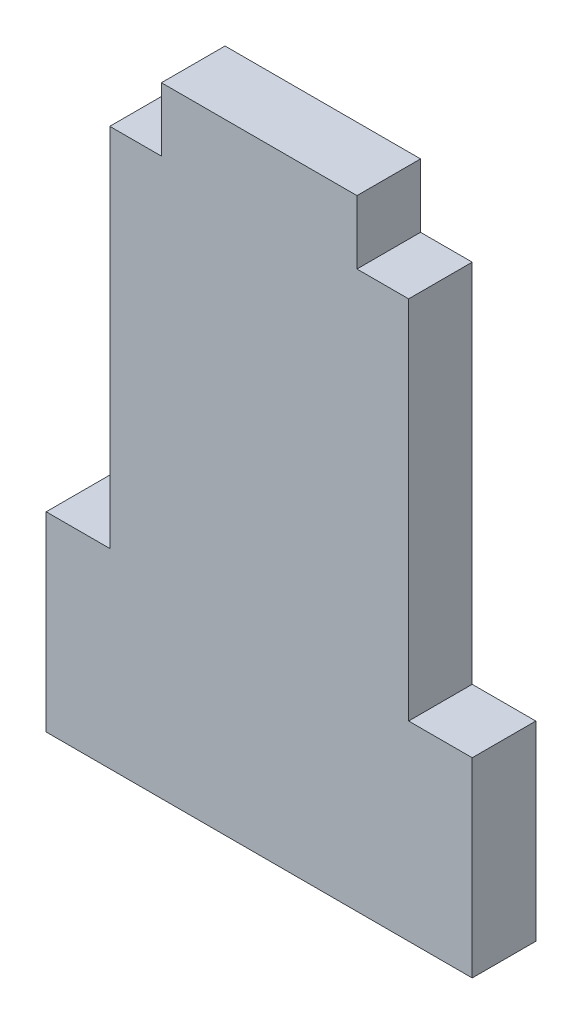
from build123d import *

# Parameters (mm, degrees)
AUFSATZ_LINEAR_AUSTRAGEN1_DEPTH = 4


with BuildPart() as part:
    # Skizze1 → Aufsatz-Linear austragen1 (new body)
    with BuildSketch(Plane.XY):
        Polygon((-13.4, 0), (-13.4, 12), (-9.4, 12), (-9.4, 35), (-6.15, 35), (-6.15, 39), (6.15, 39), (6.15, 35), (9.4, 35), (9.4, 12), (13.4, 12), (13.4, 0), align=None)
    extrude(amount=AUFSATZ_LINEAR_AUSTRAGEN1_DEPTH)


solid = part.part
